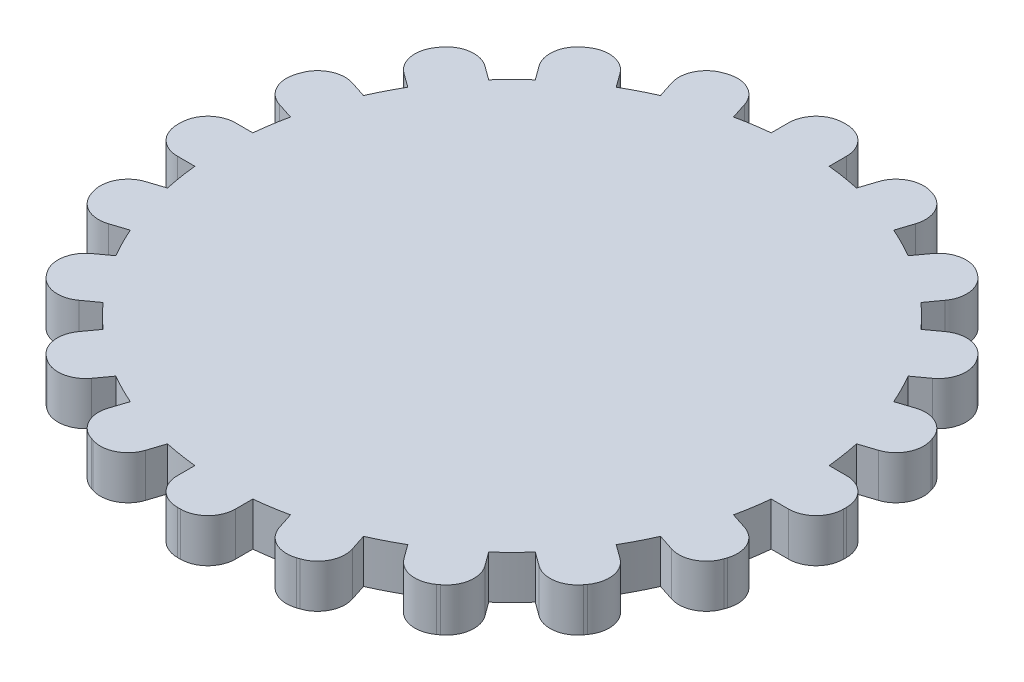
from build123d import *

# Parameters (mm, degrees)
BOSS_EXTRUDE1_DEPTH = 3
BOSS_EXTRUDE2_DEPTH = 3


with BuildPart() as part:
    # Sketch1 → Boss-Extrude1 (new body)
    with BuildSketch(Plane(origin=(0, 0, 0), x_dir=(1, 0, 0), z_dir=(0, 1, 0))):
        with BuildLine():
            Line((2.5, 1.5), (2.5, 0))
            Line((2.5, 0), (13, 0))
            Line((13, 0), (13, 0.1))
            ThreePointArc((13, 0.1), (12.443502884, 1.443502884), (11.1, 2))
            Line((11.1, 2), (9.797958971, 2))
            ThreePointArc((9.797958971, 2), (9.510565163, 3.090169944), (9.102285822, 4.141061797))
            Line((9.102285822, 4.141061797), (10.155659142, 4.906382312))
            ThreePointArc((10.155659142, 4.906382312), (10.91547501, 6.146289117), (10.575999452, 7.56030658))
            Line((10.575999452, 7.56030658), (10.458442402, 7.722109979))
            ThreePointArc((10.458442402, 7.722109979), (9.218535596, 8.481925847), (7.804518133, 8.142450289))
            Line((7.804518133, 8.142450289), (6.751144813, 7.377129775))
            ThreePointArc((6.751144813, 7.377129775), (5.877852523, 8.090169944), (4.929848865, 8.700378737))
            Line((4.929848865, 8.700378737), (5.33220167, 9.938693342))
            ThreePointArc((5.33220167, 9.938693342), (5.218106685, 11.388407581), (4.112326579, 12.332833012))
            Line((4.112326579, 12.332833012), (3.922115275, 12.394636411))
            ThreePointArc((3.922115275, 12.394636411), (2.472401036, 12.280541426), (1.527975605, 11.17476132))
            Line((1.527975605, 11.17476132), (1.1256228, 9.936446715))
            ThreePointArc((1.1256228, 9.936446715), (0.563707749, 9.984099037), (0, 10))
            Line((0, 10), (0, 1.5))
            Line((0, 1.5), (2.5, 1.5))
        make_face()
        with BuildLine():
            Line((-13, 0), (-2.5, 0))
            Line((-2.5, 0), (-2.5, 1.5))
            Line((-2.5, 1.5), (0, 1.5))
            Line((0, 1.5), (0, 10))
            ThreePointArc((0, 10), (-0.563707749, 9.984099037), (-1.1256228, 9.936446715))
            Line((-1.1256228, 9.936446715), (-1.527975605, 11.17476132))
            ThreePointArc((-1.527975605, 11.17476132), (-2.472401036, 12.280541426), (-3.922115275, 12.394636411))
            Line((-3.922115275, 12.394636411), (-4.112326579, 12.332833012))
            ThreePointArc((-4.112326579, 12.332833012), (-5.218106685, 11.388407581), (-5.33220167, 9.938693342))
            Line((-5.33220167, 9.938693342), (-4.929848865, 8.700378737))
            ThreePointArc((-4.929848865, 8.700378737), (-5.877852523, 8.090169944), (-6.751144813, 7.377129775))
            Line((-6.751144813, 7.377129775), (-7.804518133, 8.142450289))
            ThreePointArc((-7.804518133, 8.142450289), (-9.218535596, 8.481925847), (-10.458442402, 7.722109979))
            Line((-10.458442402, 7.722109979), (-10.575999452, 7.56030658))
            ThreePointArc((-10.575999452, 7.56030658), (-10.91547501, 6.146289117), (-10.155659142, 4.906382312))
            Line((-10.155659142, 4.906382312), (-9.102285822, 4.141061797))
            ThreePointArc((-9.102285822, 4.141061797), (-9.510565163, 3.090169944), (-9.797958971, 2))
            Line((-9.797958971, 2), (-11.1, 2))
            ThreePointArc((-11.1, 2), (-12.443502884, 1.443502884), (-13, 0.1))
            Line((-13, 0.1), (-13, 0))
        make_face()
        with BuildLine():
            ThreePointArc((-1.1256228, -9.936446715), (-0.563707749, -9.984099037), (0, -10))
            Line((0, -10), (0, -1.5))
            Line((0, -1.5), (-2.5, -1.5))
            Line((-2.5, -1.5), (-2.5, 0))
            Line((-2.5, 0), (-13, 0))
            Line((-13, 0), (-13, -0.1))
            ThreePointArc((-13, -0.1), (-12.443502884, -1.443502884), (-11.1, -2))
            Line((-11.1, -2), (-9.797958971, -2))
            ThreePointArc((-9.797958971, -2), (-9.510565163, -3.090169944), (-9.102285822, -4.141061797))
            Line((-9.102285822, -4.141061797), (-10.155659142, -4.906382312))
            ThreePointArc((-10.155659142, -4.906382312), (-10.91547501, -6.146289117), (-10.575999452, -7.56030658))
            Line((-10.575999452, -7.56030658), (-10.458442402, -7.722109979))
            ThreePointArc((-10.458442402, -7.722109979), (-9.218535596, -8.481925847), (-7.804518133, -8.142450289))
            Line((-7.804518133, -8.142450289), (-6.751144813, -7.377129775))
            ThreePointArc((-6.751144813, -7.377129775), (-5.877852523, -8.090169944), (-4.929848865, -8.700378737))
            Line((-4.929848865, -8.700378737), (-5.33220167, -9.938693342))
            ThreePointArc((-5.33220167, -9.938693342), (-5.218106685, -11.388407581), (-4.112326579, -12.332833012))
            Line((-4.112326579, -12.332833012), (-3.922115275, -12.394636411))
            ThreePointArc((-3.922115275, -12.394636411), (-2.472401036, -12.280541426), (-1.527975605, -11.17476132))
            Line((-1.527975605, -11.17476132), (-1.1256228, -9.936446715))
        make_face()
        with BuildLine():
            Line((0, -1.5), (0, -10))
            ThreePointArc((0, -10), (0.563707749, -9.984099037), (1.1256228, -9.936446715))
            Line((1.1256228, -9.936446715), (1.527975605, -11.17476132))
            ThreePointArc((1.527975605, -11.17476132), (2.472401036, -12.280541426), (3.922115275, -12.394636411))
            Line((3.922115275, -12.394636411), (4.112326579, -12.332833012))
            ThreePointArc((4.112326579, -12.332833012), (5.218106685, -11.388407581), (5.33220167, -9.938693342))
            Line((5.33220167, -9.938693342), (4.929848865, -8.700378737))
            ThreePointArc((4.929848865, -8.700378737), (5.877852523, -8.090169944), (6.751144813, -7.377129775))
            Line((6.751144813, -7.377129775), (7.804518133, -8.142450289))
            ThreePointArc((7.804518133, -8.142450289), (9.218535596, -8.481925847), (10.458442402, -7.722109979))
            Line((10.458442402, -7.722109979), (10.575999452, -7.56030658))
            ThreePointArc((10.575999452, -7.56030658), (10.91547501, -6.146289117), (10.155659142, -4.906382312))
            Line((10.155659142, -4.906382312), (9.102285822, -4.141061797))
            ThreePointArc((9.102285822, -4.141061797), (9.510565163, -3.090169944), (9.797958971, -2))
            Line((9.797958971, -2), (11.1, -2))
            ThreePointArc((11.1, -2), (12.443502884, -1.443502884), (13, -0.1))
            Line((13, -0.1), (13, 0))
            Line((13, 0), (2.5, 0))
            Line((2.5, 0), (2.5, -1.5))
            Line((2.5, -1.5), (0, -1.5))
        make_face()
    extrude(amount=BOSS_EXTRUDE1_DEPTH)

    # Sketch2 → Boss-Extrude2 (add)
    with BuildSketch(Plane(origin=(0, 0, 0), x_dir=(1, 0, 0), z_dir=(0, 1, 0))):
        with BuildLine():
            Line((-23, -0.1), (-23, 0.1))
            ThreePointArc((-23, 0.1), (-22.443502884, 1.443502884), (-21.1, 2))
            Line((-21.1, 2), (-19.899748742, 2))
            ThreePointArc((-19.899748742, 2), (-19.753766812, 3.128689301), (-19.543819703, 4.247247513))
            Line((-19.543819703, 4.247247513), (-20.685326483, 4.618145549))
            ThreePointArc((-20.685326483, 4.618145549), (-21.791106589, 5.56257098), (-21.905201574, 7.012285219))
            Line((-21.905201574, 7.012285219), (-21.843398175, 7.202496522))
            ThreePointArc((-21.843398175, 7.202496522), (-20.898972744, 8.308276629), (-19.449258505, 8.422371614))
            Line((-19.449258505, 8.422371614), (-18.307751725, 8.051473578))
            ThreePointArc((-18.307751725, 8.051473578), (-17.820130484, 9.079809995), (-17.274805421, 10.078744846))
            Line((-17.274805421, 10.078744846), (-18.245829086, 10.784234835))
            ThreePointArc((-18.245829086, 10.784234835), (-19.005644954, 12.02414164), (-18.666169396, 13.438159103))
            Line((-18.666169396, 13.438159103), (-18.548612345, 13.599962502))
            ThreePointArc((-18.548612345, 13.599962502), (-17.30870554, 14.35977837), (-15.894688077, 14.020302812))
            Line((-15.894688077, 14.020302812), (-14.923664412, 13.314812824))
            ThreePointArc((-14.923664412, 13.314812824), (-14.142135624, 14.142135624), (-13.314812824, 14.923664412))
            Line((-13.314812824, 14.923664412), (-14.020302812, 15.894688077))
            ThreePointArc((-14.020302812, 15.894688077), (-14.35977837, 17.30870554), (-13.599962502, 18.548612345))
            Line((-13.599962502, 18.548612345), (-13.438159103, 18.666169396))
            ThreePointArc((-13.438159103, 18.666169396), (-12.02414164, 19.005644954), (-10.784234835, 18.245829086))
            Line((-10.784234835, 18.245829086), (-10.078744846, 17.274805421))
            ThreePointArc((-10.078744846, 17.274805421), (-9.079809995, 17.820130484), (-8.051473578, 18.307751725))
            Line((-8.051473578, 18.307751725), (-8.422371614, 19.449258505))
            ThreePointArc((-8.422371614, 19.449258505), (-8.308276629, 20.898972744), (-7.202496522, 21.843398175))
            Line((-7.202496522, 21.843398175), (-7.012285219, 21.905201574))
            ThreePointArc((-7.012285219, 21.905201574), (-5.56257098, 21.791106589), (-4.618145549, 20.685326483))
            Line((-4.618145549, 20.685326483), (-4.247247513, 19.543819703))
            ThreePointArc((-4.247247513, 19.543819703), (-3.128689301, 19.753766812), (-2, 19.899748742))
            Line((-2, 19.899748742), (-2, 21.1))
            ThreePointArc((-2, 21.1), (-1.443502884, 22.443502884), (-0.1, 23))
            Line((-0.1, 23), (0.1, 23))
            ThreePointArc((0.1, 23), (1.443502884, 22.443502884), (2, 21.1))
            Line((2, 21.1), (2, 19.899748742))
            ThreePointArc((2, 19.899748742), (3.128689301, 19.753766812), (4.247247513, 19.543819703))
            Line((4.247247513, 19.543819703), (4.618145549, 20.685326483))
            ThreePointArc((4.618145549, 20.685326483), (5.56257098, 21.791106589), (7.012285219, 21.905201574))
            Line((7.012285219, 21.905201574), (7.202496522, 21.843398175))
            ThreePointArc((7.202496522, 21.843398175), (8.308276629, 20.898972744), (8.422371614, 19.449258505))
            Line((8.422371614, 19.449258505), (8.051473578, 18.307751725))
            ThreePointArc((8.051473578, 18.307751725), (9.079809995, 17.820130484), (10.078744846, 17.274805421))
            Line((10.078744846, 17.274805421), (10.784234835, 18.245829086))
            ThreePointArc((10.784234835, 18.245829086), (12.02414164, 19.005644954), (13.438159103, 18.666169396))
            Line((13.438159103, 18.666169396), (13.599962502, 18.548612345))
            ThreePointArc((13.599962502, 18.548612345), (14.35977837, 17.30870554), (14.020302812, 15.894688077))
            Line((14.020302812, 15.894688077), (13.314812824, 14.923664412))
            ThreePointArc((13.314812824, 14.923664412), (14.142135624, 14.142135624), (14.923664412, 13.314812824))
            Line((14.923664412, 13.314812824), (15.894688077, 14.020302812))
            ThreePointArc((15.894688077, 14.020302812), (17.30870554, 14.35977837), (18.548612345, 13.599962502))
            Line((18.548612345, 13.599962502), (18.666169396, 13.438159103))
            ThreePointArc((18.666169396, 13.438159103), (19.005644954, 12.02414164), (18.245829086, 10.784234835))
            Line((18.245829086, 10.784234835), (17.274805421, 10.078744846))
            ThreePointArc((17.274805421, 10.078744846), (17.820130484, 9.079809995), (18.307751725, 8.051473578))
            Line((18.307751725, 8.051473578), (19.449258505, 8.422371614))
            ThreePointArc((19.449258505, 8.422371614), (20.898972744, 8.308276629), (21.843398175, 7.202496522))
            Line((21.843398175, 7.202496522), (21.905201574, 7.012285219))
            ThreePointArc((21.905201574, 7.012285219), (21.791106589, 5.56257098), (20.685326483, 4.618145549))
            Line((20.685326483, 4.618145549), (19.543819703, 4.247247513))
            ThreePointArc((19.543819703, 4.247247513), (19.753766812, 3.128689301), (19.899748742, 2))
            Line((19.899748742, 2), (21.1, 2))
            ThreePointArc((21.1, 2), (22.443502884, 1.443502884), (23, 0.1))
            Line((23, 0.1), (23, -0.1))
            ThreePointArc((23, -0.1), (22.443502884, -1.443502884), (21.1, -2))
            Line((21.1, -2), (19.899748742, -2))
            ThreePointArc((19.899748742, -2), (19.753766812, -3.128689301), (19.543819703, -4.247247513))
            Line((19.543819703, -4.247247513), (20.685326483, -4.618145549))
            ThreePointArc((20.685326483, -4.618145549), (21.791106589, -5.56257098), (21.905201574, -7.012285219))
            Line((21.905201574, -7.012285219), (21.843398175, -7.202496522))
            ThreePointArc((21.843398175, -7.202496522), (20.898972744, -8.308276629), (19.449258505, -8.422371614))
            Line((19.449258505, -8.422371614), (18.307751725, -8.051473578))
            ThreePointArc((18.307751725, -8.051473578), (17.820130484, -9.079809995), (17.274805421, -10.078744846))
            Line((17.274805421, -10.078744846), (18.245829086, -10.784234835))
            ThreePointArc((18.245829086, -10.784234835), (19.005644954, -12.02414164), (18.666169396, -13.438159103))
            Line((18.666169396, -13.438159103), (18.548612345, -13.599962502))
            ThreePointArc((18.548612345, -13.599962502), (17.30870554, -14.35977837), (15.894688077, -14.020302812))
            Line((15.894688077, -14.020302812), (14.923664412, -13.314812824))
            ThreePointArc((14.923664412, -13.314812824), (14.142135624, -14.142135624), (13.314812824, -14.923664412))
            Line((13.314812824, -14.923664412), (14.020302812, -15.894688077))
            ThreePointArc((14.020302812, -15.894688077), (14.35977837, -17.30870554), (13.599962502, -18.548612345))
            Line((13.599962502, -18.548612345), (13.438159103, -18.666169396))
            ThreePointArc((13.438159103, -18.666169396), (12.02414164, -19.005644954), (10.784234835, -18.245829086))
            Line((10.784234835, -18.245829086), (10.078744846, -17.274805421))
            ThreePointArc((10.078744846, -17.274805421), (9.079809995, -17.820130484), (8.051473578, -18.307751725))
            Line((8.051473578, -18.307751725), (8.422371614, -19.449258505))
            ThreePointArc((8.422371614, -19.449258505), (8.308276629, -20.898972744), (7.202496522, -21.843398175))
            Line((7.202496522, -21.843398175), (7.012285219, -21.905201574))
            ThreePointArc((7.012285219, -21.905201574), (5.56257098, -21.791106589), (4.618145549, -20.685326483))
            Line((4.618145549, -20.685326483), (4.247247513, -19.543819703))
            ThreePointArc((4.247247513, -19.543819703), (3.128689301, -19.753766812), (2, -19.899748742))
            Line((2, -19.899748742), (2, -21.1))
            ThreePointArc((2, -21.1), (1.443502884, -22.443502884), (0.1, -23))
            Line((0.1, -23), (-0.1, -23))
            ThreePointArc((-0.1, -23), (-1.443502884, -22.443502884), (-2, -21.1))
            Line((-2, -21.1), (-2, -19.899748742))
            ThreePointArc((-2, -19.899748742), (-3.128689301, -19.753766812), (-4.247247513, -19.543819703))
            Line((-4.247247513, -19.543819703), (-4.618145549, -20.685326483))
            ThreePointArc((-4.618145549, -20.685326483), (-5.56257098, -21.791106589), (-7.012285219, -21.905201574))
            Line((-7.012285219, -21.905201574), (-7.202496522, -21.843398175))
            ThreePointArc((-7.202496522, -21.843398175), (-8.308276629, -20.898972744), (-8.422371614, -19.449258505))
            Line((-8.422371614, -19.449258505), (-8.051473578, -18.307751725))
            ThreePointArc((-8.051473578, -18.307751725), (-9.079809995, -17.820130484), (-10.078744846, -17.274805421))
            Line((-10.078744846, -17.274805421), (-10.784234835, -18.245829086))
            ThreePointArc((-10.784234835, -18.245829086), (-12.02414164, -19.005644954), (-13.438159103, -18.666169396))
            Line((-13.438159103, -18.666169396), (-13.599962502, -18.548612345))
            ThreePointArc((-13.599962502, -18.548612345), (-14.35977837, -17.30870554), (-14.020302812, -15.894688077))
            Line((-14.020302812, -15.894688077), (-13.314812824, -14.923664412))
            ThreePointArc((-13.314812824, -14.923664412), (-14.142135624, -14.142135624), (-14.923664412, -13.314812824))
            Line((-14.923664412, -13.314812824), (-15.894688077, -14.020302812))
            ThreePointArc((-15.894688077, -14.020302812), (-17.30870554, -14.35977837), (-18.548612345, -13.599962502))
            Line((-18.548612345, -13.599962502), (-18.666169396, -13.438159103))
            ThreePointArc((-18.666169396, -13.438159103), (-19.005644954, -12.02414164), (-18.245829086, -10.784234835))
            Line((-18.245829086, -10.784234835), (-17.274805421, -10.078744846))
            ThreePointArc((-17.274805421, -10.078744846), (-17.820130484, -9.079809995), (-18.307751725, -8.051473578))
            Line((-18.307751725, -8.051473578), (-19.449258505, -8.422371614))
            ThreePointArc((-19.449258505, -8.422371614), (-20.898972744, -8.308276629), (-21.843398175, -7.202496522))
            Line((-21.843398175, -7.202496522), (-21.905201574, -7.012285219))
            ThreePointArc((-21.905201574, -7.012285219), (-21.791106589, -5.56257098), (-20.685326483, -4.618145549))
            Line((-20.685326483, -4.618145549), (-19.543819703, -4.247247513))
            ThreePointArc((-19.543819703, -4.247247513), (-19.753766812, -3.128689301), (-19.899748742, -2))
            Line((-19.899748742, -2), (-21.1, -2))
            ThreePointArc((-21.1, -2), (-22.443502884, -1.443502884), (-23, -0.1))
        make_face()
    extrude(amount=BOSS_EXTRUDE2_DEPTH)


solid = part.part
